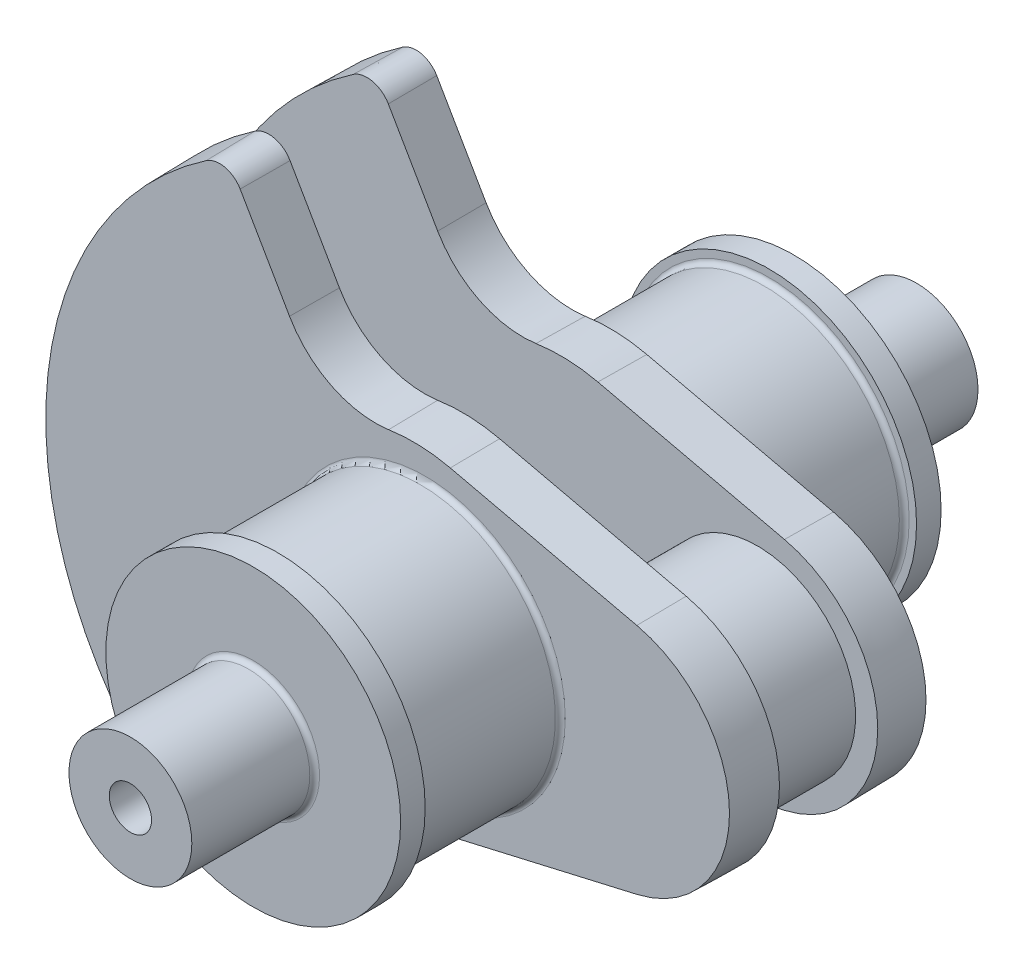
from build123d import *

# Parameters (mm, degrees)
BOSS_EXTRUDE1_DEPTH = 10
BOSS_EXTRUDE1_TAPER = 1
SKETCH2_R           = 27.5
BOSS_EXTRUDE2_DEPTH = 30
SKETCH3_R           = 30
BOSS_EXTRUDE3_DEPTH = 5
FILLET1_R           = 1
SKETCH4_R           = 12.5
BOSS_EXTRUDE4_DEPTH = 25
FILLET2_R           = 1
SKETCH5_R           = 4.302920272
CUT_EXTRUDE1_DEPTH  = 12
SKETCH8_R           = 20
BOSS_EXTRUDE6_DEPTH = 10


with BuildPart() as part:
    # Sketch1 → Boss-Extrude1 (new body)
    with BuildSketch(Plane.XY):
        with BuildLine():
            Line((5.5125, 23.871789706), (-32.4625, 32.641018577))
            ThreePointArc((-32.4625, 32.641018577), (-38.740972489, 33.47633268), (-45.064451317, 33.114971431))
            ThreePointArc((-45.064451317, 33.114971431), (-56.55780319, 34.98230856), (-65.063174389, 42.934839352))
            Line((-65.063174389, 42.934839352), (-75.107927207, 60.332861583))
            ThreePointArc((-75.107927207, 60.332861583), (-78.325687671, 62.707555486), (-82.255058099, 61.963780268))
            ThreePointArc((-82.255058099, 61.963780268), (-115, 0), (-82.255058099, -61.963780268))
            ThreePointArc((-82.255058099, -61.963780268), (-78.325687671, -62.707555486), (-75.107927207, -60.332861583))
            Line((-75.107927207, -60.332861583), (-65.063174389, -42.934839352))
            ThreePointArc((-65.063174389, -42.934839352), (-56.55780319, -34.98230856), (-45.064451317, -33.114971431))
            ThreePointArc((-45.064451317, -33.114971431), (-38.740972489, -33.47633268), (-32.4625, -32.641018577))
            Line((-32.4625, -32.641018577), (5.5125, -23.871789706))
            ThreePointArc((5.5125, -23.871789706), (24.5, 0), (5.5125, 23.871789706))
        make_face()
    extrude(amount=BOSS_EXTRUDE1_DEPTH, taper=BOSS_EXTRUDE1_TAPER)

    # Sketch2 → Boss-Extrude2 (add)
    with BuildSketch(Plane.XY.offset(10)):
        with Locations((-37.598524934, 0)):
            Circle(SKETCH2_R)
    extrude(amount=BOSS_EXTRUDE2_DEPTH)

    # Sketch3 → Boss-Extrude3 (add)
    with BuildSketch(Plane.XY.offset(40)):
        with Locations((-37.598524934, 0)):
            Circle(SKETCH3_R)
    extrude(amount=BOSS_EXTRUDE3_DEPTH)

    # Fillet1
    fillet1_edges = [part.edges().sort_by_distance(p)[0] for p in [
        (-65.098524934, 0, 10),
        (-65.098524934, 0, 40),
    ]]
    fillet(fillet1_edges, radius=FILLET1_R)

    # Sketch4 → Boss-Extrude4 (add)
    with BuildSketch(Plane.XY.offset(45)):
        with Locations((-37.598524934, 0)):
            Circle(SKETCH4_R)
    extrude(amount=BOSS_EXTRUDE4_DEPTH)

    # Fillet2
    fillet2_edges = [part.edges().sort_by_distance(p)[0] for p in [
        (-50.098524934, 0, 45),
    ]]
    fillet(fillet2_edges, radius=FILLET2_R)

    # Sketch5 → Cut-Extrude1 (cut)
    with BuildSketch(Plane.XY.offset(70)):
        with Locations((-37.598524934, 0)):
            Circle(SKETCH5_R)
    extrude(amount=-CUT_EXTRUDE1_DEPTH, mode=Mode.SUBTRACT)

    # Sketch8 → Boss-Extrude6 (add)
    with BuildSketch(Plane(origin=(0, 0, 0), x_dir=(-1, 0, 0), z_dir=(0, 0, -1))):
        Circle(SKETCH8_R)
    extrude(amount=BOSS_EXTRUDE6_DEPTH)

    # Mirror7: part across plane


with BuildPart() as part_1:
    add(part.part)
    add(part.part.mirror(Plane(origin=(0, 0, -10), x_dir=(1, 0, 0), z_dir=(0, 0, -1))))


solid = part_1.part
